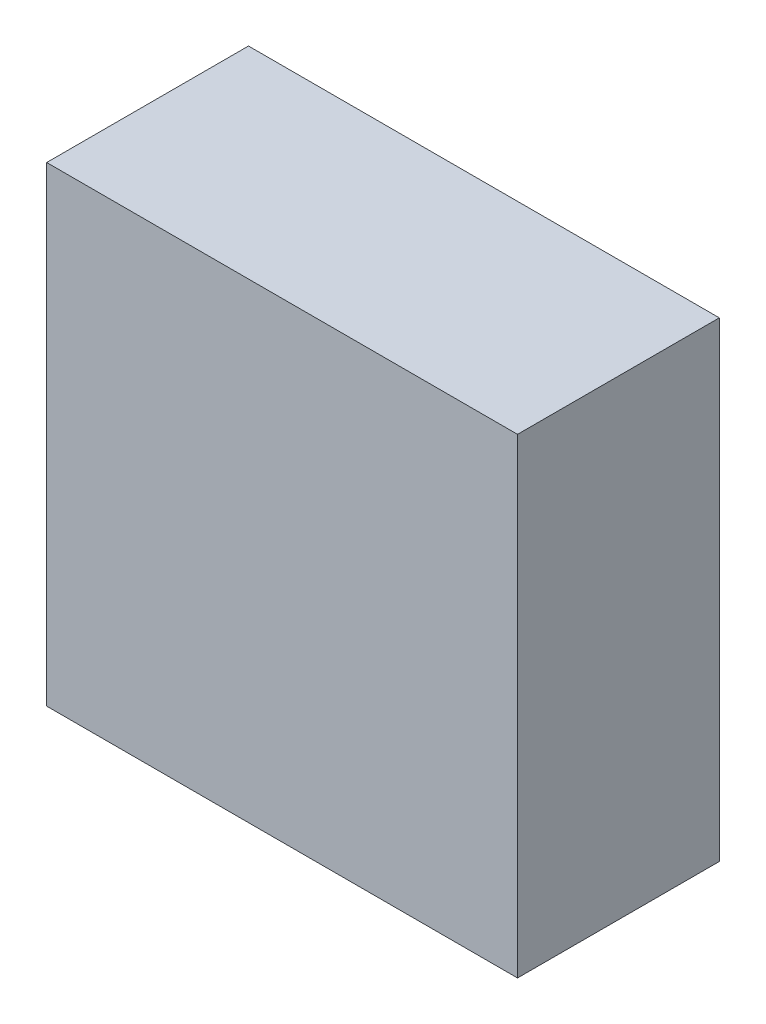
from build123d import *

# Parameters (mm, degrees)
SKETCH1_W           = 14
SKETCH1_H           = 14
BOSS_EXTRUDE1_DEPTH = 6


with BuildPart() as part:
    # Sketch1 → Boss-Extrude1 (new body)
    with BuildSketch(Plane.XY):
        Rectangle(SKETCH1_W, SKETCH1_H)
    extrude(amount=BOSS_EXTRUDE1_DEPTH)


solid = part.part
